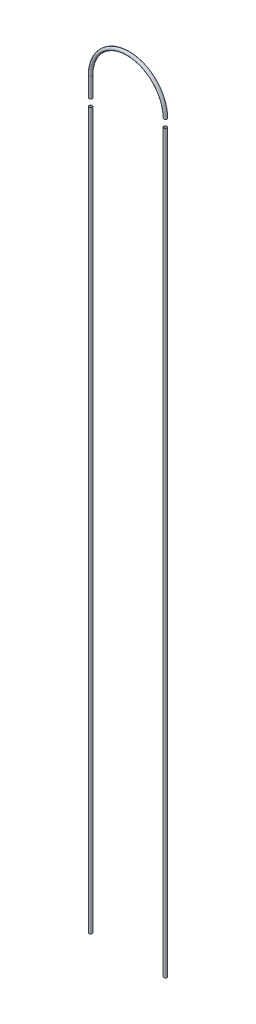
from build123d import *

# Parameters (mm, degrees)
SWEEP_THIN1_PROFILE_R   = 30
SWEEP_THIN1_PROFILE_R_2 = 27
SWEEP_THIN3_PROFILE_R   = 30
SWEEP_THIN3_PROFILE_R_2 = 27
SWEEP_THIN4_PROFILE_R   = 30
SWEEP_THIN4_PROFILE_R_2 = 27


with BuildPart() as part:
    # Sweep-Thin1: sweep along a curve in space
    with BuildLine() as sweep_thin1_path:
        Line((-23039.401391801, 11528.530628552, 40208.375315098), (-23039.401391801, 11163.190412186, 40208.375315098))
        ThreePointArc((-23039.401391801, 11528.530628552, 40208.375315098), (-22349.401391801, 12218.530628552, 40208.375315098), (-21659.401391801, 11528.530628552, 40208.375315098))
    # Sweep-Thin1 profile (on start of the path) → Sweep-Thin1 (sweep)
    with BuildSketch(Plane(origin=(-21659.401391801, 11528.530628552, 40208.375315098), x_dir=(1, 0, 0), z_dir=(0, 1, 0))):
        Circle(SWEEP_THIN1_PROFILE_R)
        Circle(SWEEP_THIN1_PROFILE_R_2, mode=Mode.SUBTRACT)
    sweep(path=sweep_thin1_path.line)


with BuildPart() as body_2:
    # Sweep-Thin3: sweep along a curve in space
    with BuildLine() as sweep_thin3_path:
        Line((-21659.401391801, 11384.945711664, 40208.375315098), (-21659.401391801, -2185.054288336, 40208.375315098))
    # Sweep-Thin3 profile (on start of the path) → Sweep-Thin3 (sweep)
    with BuildSketch(Plane(origin=(-21659.401391801, 11384.945711664, 40208.375315098), x_dir=(0, 0, -1), z_dir=(0, -1, 0))):
        Circle(SWEEP_THIN3_PROFILE_R)
        Circle(SWEEP_THIN3_PROFILE_R_2, mode=Mode.SUBTRACT)
    sweep(path=sweep_thin3_path.line)


with BuildPart() as body_3:
    # Sweep-Thin4: sweep along a curve in space
    with BuildLine() as sweep_thin4_path:
        Line((-23039.401391872, 11026.348648105, 40208.375307126), (-23039.401391872, -2173.651351895, 40208.375307126))
    # Sweep-Thin4 profile (on start of the path) → Sweep-Thin4 (sweep)
    with BuildSketch(Plane(origin=(-23039.401391872, 11026.348648105, 40208.375307126), x_dir=(0, 0, -1), z_dir=(0, -1, 0))):
        Circle(SWEEP_THIN4_PROFILE_R)
        Circle(SWEEP_THIN4_PROFILE_R_2, mode=Mode.SUBTRACT)
    sweep(path=sweep_thin4_path.line)


solid = Compound([part.part, body_2.part, body_3.part])
